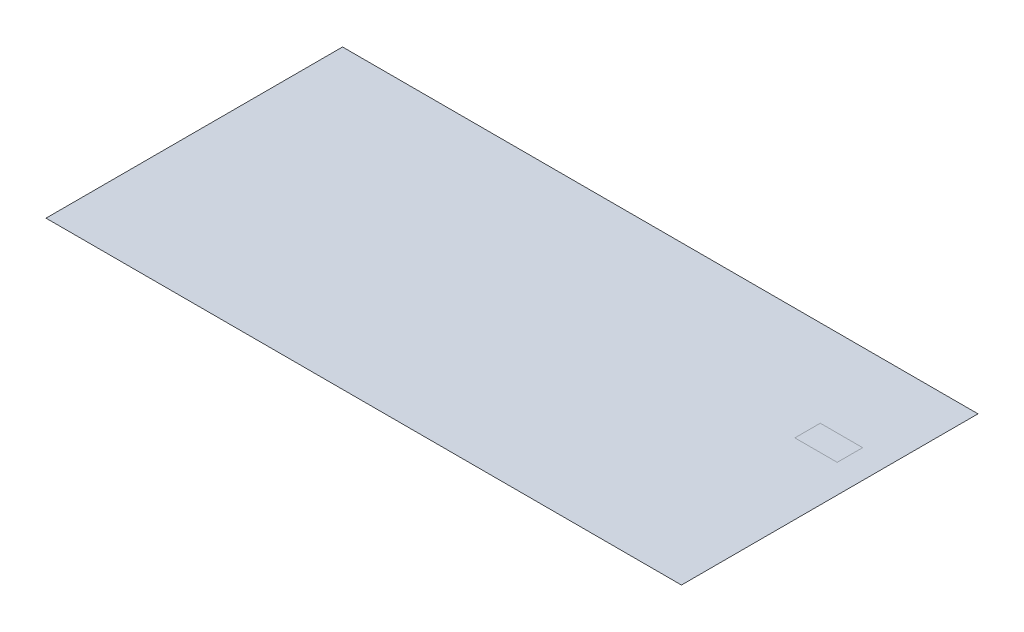
from build123d import *

# Parameters (mm, degrees)
SKETCH1_W           = 15000
SKETCH1_H           = 7000
BOSS_EXTRUDE2_DEPTH = 0.001


with BuildPart() as part:
    # Sketch1 → Boss-Extrude2 (new body)
    with BuildSketch(Plane(origin=(0, 0, 0), x_dir=(1, 0, 0), z_dir=(0, 1, 0))):
        with Locations((7500, -3500)):
            Rectangle(SKETCH1_W, SKETCH1_H)
    extrude(amount=-BOSS_EXTRUDE2_DEPTH)


solid = part.part
